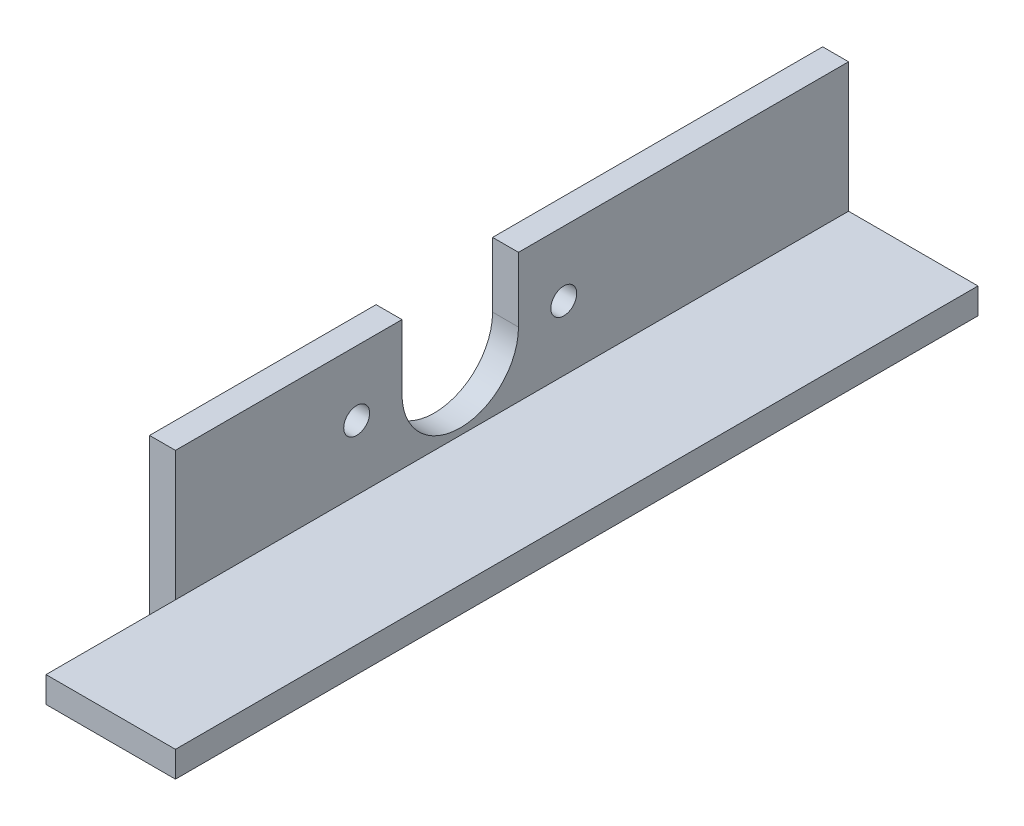
from build123d import *

# Parameters (mm, degrees)
BOSS_EXTRUDE1_DEPTH = 196.85
SKETCH2_W           = 31.75
SKETCH2_H           = 38.1
CUT_EXTRUDE1_DEPTH  = 6.35
SKETCH3_R           = 3.175
CUT_EXTRUDE2_DEPTH  = 7.35


with BuildPart() as part:
    # Sketch1 → Boss-Extrude1 (new body)
    with BuildSketch(Plane.XY):
        Polygon((0, 0), (0, 38.1), (6.35, 38.1), (6.35, 6.35), (38.1, 6.35), (38.1, 0), align=None)
    extrude(amount=BOSS_EXTRUDE1_DEPTH)

    # Sketch2 → Cut-Extrude1 (cut)
    with BuildSketch(Plane(origin=(0, 0, 0), x_dir=(0, 0, -1), z_dir=(1, 0, 0))):
        with Locations((-180.975, 19.05)):
            Rectangle(SKETCH2_W, SKETCH2_H)
    extrude(amount=CUT_EXTRUDE1_DEPTH, mode=Mode.SUBTRACT)

    # Sketch3 → Cut-Extrude2 (cut, through all)
    with BuildSketch(Plane(origin=(6.35, 0, 0), x_dir=(0, 0, -1), z_dir=(1, 0, 0))):
        with Locations((-120.65, 22.225)):
            Circle(SKETCH3_R)
        with Locations((-69.85, 22.225)):
            Circle(SKETCH3_R)
        with BuildLine():
            Line((-109.5375, 22.225), (-109.5375, 38.1))
            Line((-109.5375, 38.1), (-80.9625, 38.1))
            Line((-80.9625, 38.1), (-80.9625, 22.225))
            ThreePointArc((-80.9625, 22.225), (-95.25, 7.9375), (-109.5375, 22.225))
        make_face()
    extrude(amount=-CUT_EXTRUDE2_DEPTH, mode=Mode.SUBTRACT)


solid = part.part
